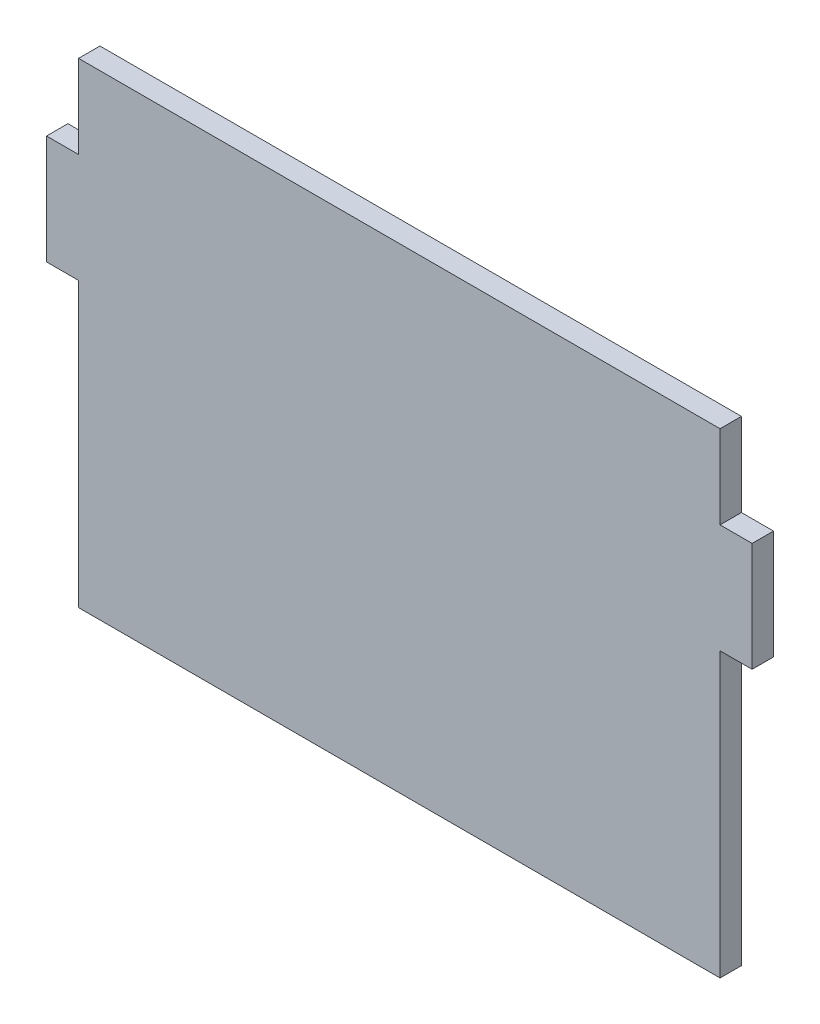
from build123d import *

# Parameters (mm, degrees)
Y_KSEKLIK_EKSTR_ZYON1_DEPTH = 10


with BuildPart() as part:
    # Çizim1 → Yükseklik-Ekstrüzyon1 (new body)
    with BuildSketch(Plane.XY):
        Polygon((-150, -111.235), (-150, 21.285), (-165, 21.285), (-165, 72.285), (-150, 72.285), (-150, 111.235), (150, 111.235), (150, 72.285), (165, 72.285), (165, 21.285), (150, 21.285), (150, -111.235), align=None)
    extrude(amount=Y_KSEKLIK_EKSTR_ZYON1_DEPTH)


solid = part.part
